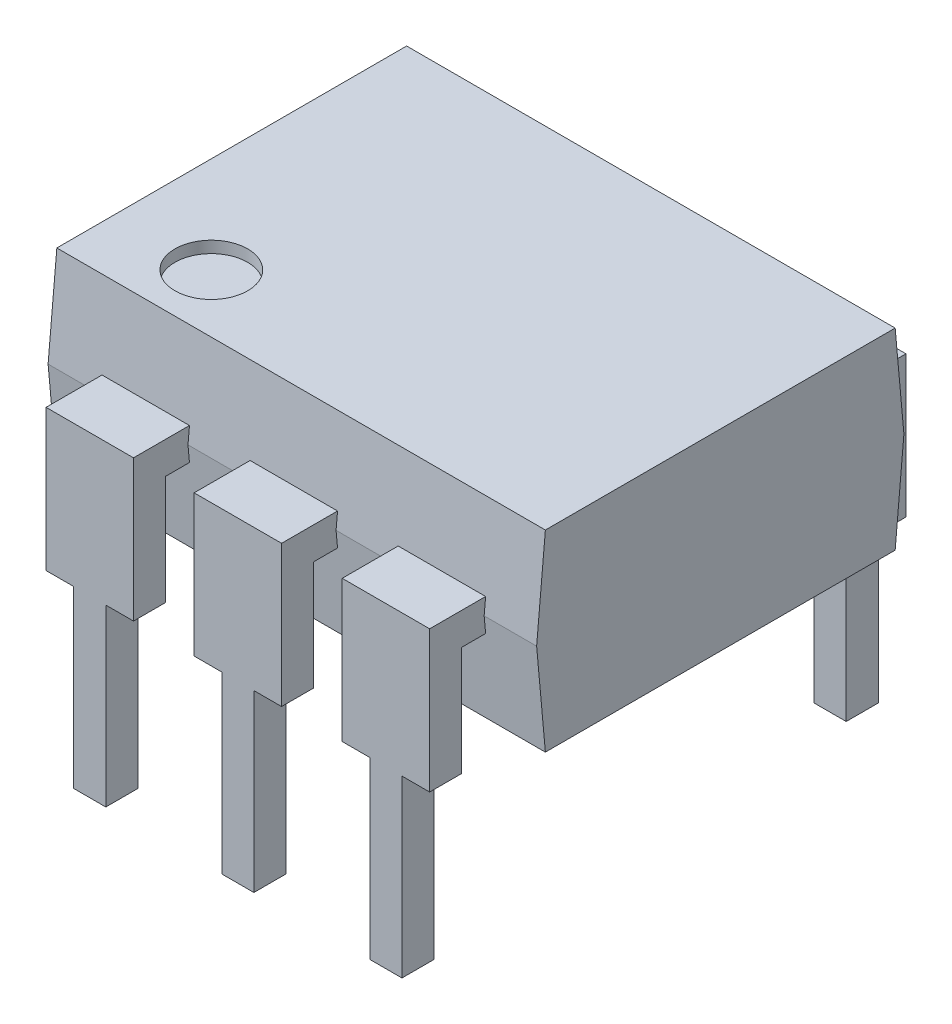
from build123d import *

# Parameters (mm, degrees)
BOSS_EXTRUDE1_DEPTH     = 8.38
SKETCH5_W               = 1.5
SKETCH5_H               = 1.085
BOSS_EXTRUDE2_DEPTH     = 0.275
SKETCH5_3_W             = 1.5
SKETCH5_3_H             = 0.55
BOSS_EXTRUDE4_DEPTH     = 2.15
SKETCH3_W               = 0.55
SKETCH3_H               = 0.55
BOSS_EXTRUDE5_DEPTH     = 3.5
LPATTERN1_COUNT         = 3
LPATTERN1_PITCH         = 2.54
MIRROR3_COPY_1_SKETCH_W = 1.5
MIRROR3_COPY_1_SKETCH_H = 1.085
MIRROR3_COPY_1_DEPTH    = 0.275
MIRROR3_COPY_2_SKETCH_W = 1.5
MIRROR3_COPY_2_SKETCH_H = 1.085
MIRROR3_COPY_2_DEPTH    = 0.275
MIRROR3_COPY_3_SKETCH_W = 1.5
MIRROR3_COPY_3_SKETCH_H = 0.55
MIRROR3_COPY_3_DEPTH    = 2.15
MIRROR3_COPY_4_SKETCH_W = 1.5
MIRROR3_COPY_4_SKETCH_H = 0.55
MIRROR3_COPY_4_DEPTH    = 2.15
MIRROR3_COPY_5_SKETCH_W = 0.55
MIRROR3_COPY_5_SKETCH_H = 0.55
MIRROR3_COPY_5_DEPTH    = 3.5
MIRROR3_COPY_6_SKETCH_W = 0.55
MIRROR3_COPY_6_SKETCH_H = 0.55
MIRROR3_COPY_6_DEPTH    = 3.5
SKETCH6_R               = 0.623672025
CUT_EXTRUDE1_DEPTH      = 0.2


with BuildPart() as part:
    # Sketch2 → Boss-Extrude1 (new body)
    with BuildSketch(Plane(origin=(0, 0, 0), x_dir=(0, 0, -1), z_dir=(1, 0, 0))):
        Polygon((0, 0), (0, 3.3), (-3, 3.3), (-3.15, 1.65), (-3, 0), align=None)
    boss_extrude1 = extrude(amount=BOSS_EXTRUDE1_DEPTH)

    # Mirror2: Boss-Extrude1 across plane
    add(boss_extrude1.mirror(Plane.XY))


with BuildPart() as body_2:
    # Sketch5 → Boss-Extrude2 (new, symmetric)
    with BuildSketch(Plane(origin=(0, 1.65, 0), x_dir=(1, 0, 0), z_dir=(0, 1, 0))):
        with Locations((1.65, -3.5425)):
            Rectangle(SKETCH5_W, SKETCH5_H)
    boss_extrude2 = extrude(amount=BOSS_EXTRUDE2_DEPTH, both=True)

    # Sketch5_3 → Boss-Extrude4 (add)
    with BuildSketch(Plane(origin=(0, 1.65, 0), x_dir=(1, 0, 0), z_dir=(0, 1, 0))):
        with Locations((1.65, -3.81)):
            Rectangle(SKETCH5_3_W, SKETCH5_3_H)
    boss_extrude4 = extrude(amount=-BOSS_EXTRUDE4_DEPTH)

    # Sketch3 → Boss-Extrude5 (add)
    with BuildSketch(Plane(origin=(0, 0, 0), x_dir=(1, 0, 0), z_dir=(0, 1, 0))):
        with Locations((1.65, -3.81)):
            Rectangle(SKETCH3_W, SKETCH3_H)
    boss_extrude5 = extrude(amount=-BOSS_EXTRUDE5_DEPTH)


with BuildPart() as lpattern1_1:
    # LPattern1: Boss-Extrude2, Boss-Extrude4, Boss-Extrude5 ×3
    with Locations(*[(i * LPATTERN1_PITCH, 0, 0) for i in range(1, LPATTERN1_COUNT)]):
        add(boss_extrude2)
        add(boss_extrude4)
        add(boss_extrude5)


with BuildPart() as part_1:
    add(part.part)

    # Mirror3: Boss-Extrude2, Boss-Extrude4, Boss-Extrude5 across plane
    add(boss_extrude2.mirror(Plane.XY))
    add(boss_extrude4.mirror(Plane.XY))
    add(boss_extrude5.mirror(Plane.XY))

    # Mirror3 copy 1 sketch → Mirror3 copy 1 (add, symmetric)
    with BuildSketch(Plane(origin=(2.54, 1.65, 0), x_dir=(1, 0, 0), z_dir=(0, 1, 0))):
        with Locations((1.65, 3.5425)):
            Rectangle(MIRROR3_COPY_1_SKETCH_W, MIRROR3_COPY_1_SKETCH_H)
    extrude(amount=MIRROR3_COPY_1_DEPTH, both=True)

    # Mirror3 copy 2 sketch → Mirror3 copy 2 (add, symmetric)
    with BuildSketch(Plane(origin=(5.08, 1.65, 0), x_dir=(1, 0, 0), z_dir=(0, 1, 0))):
        with Locations((1.65, 3.5425)):
            Rectangle(MIRROR3_COPY_2_SKETCH_W, MIRROR3_COPY_2_SKETCH_H)
    extrude(amount=MIRROR3_COPY_2_DEPTH, both=True)

    # Mirror3 copy 3 sketch → Mirror3 copy 3 (add)
    with BuildSketch(Plane(origin=(2.54, 1.65, 0), x_dir=(1, 0, 0), z_dir=(0, 1, 0))):
        with Locations((1.65, 3.81)):
            Rectangle(MIRROR3_COPY_3_SKETCH_W, MIRROR3_COPY_3_SKETCH_H)
    extrude(amount=-MIRROR3_COPY_3_DEPTH)

    # Mirror3 copy 4 sketch → Mirror3 copy 4 (add)
    with BuildSketch(Plane(origin=(5.08, 1.65, 0), x_dir=(1, 0, 0), z_dir=(0, 1, 0))):
        with Locations((1.65, 3.81)):
            Rectangle(MIRROR3_COPY_4_SKETCH_W, MIRROR3_COPY_4_SKETCH_H)
    extrude(amount=-MIRROR3_COPY_4_DEPTH)

    # Mirror3 copy 5 sketch → Mirror3 copy 5 (add)
    with BuildSketch(Plane(origin=(2.54, 0, 0), x_dir=(1, 0, 0), z_dir=(0, 1, 0))):
        with Locations((1.65, 3.81)):
            Rectangle(MIRROR3_COPY_5_SKETCH_W, MIRROR3_COPY_5_SKETCH_H)
    extrude(amount=-MIRROR3_COPY_5_DEPTH)

    # Mirror3 copy 6 sketch → Mirror3 copy 6 (add)
    with BuildSketch(Plane(origin=(5.08, 0, 0), x_dir=(1, 0, 0), z_dir=(0, 1, 0))):
        with Locations((1.65, 3.81)):
            Rectangle(MIRROR3_COPY_6_SKETCH_W, MIRROR3_COPY_6_SKETCH_H)
    extrude(amount=-MIRROR3_COPY_6_DEPTH)

    # Sketch6 → Cut-Extrude1 (cut)
    with BuildSketch(Plane(origin=(0, 3.3, 0), x_dir=(1, 0, 0), z_dir=(0, 1, 0))):
        with Locations((1.65, -2)):
            Circle(SKETCH6_R)
    extrude(amount=-CUT_EXTRUDE1_DEPTH, mode=Mode.SUBTRACT)


solid = Compound([body_2.part, lpattern1_1.part, part_1.part])
